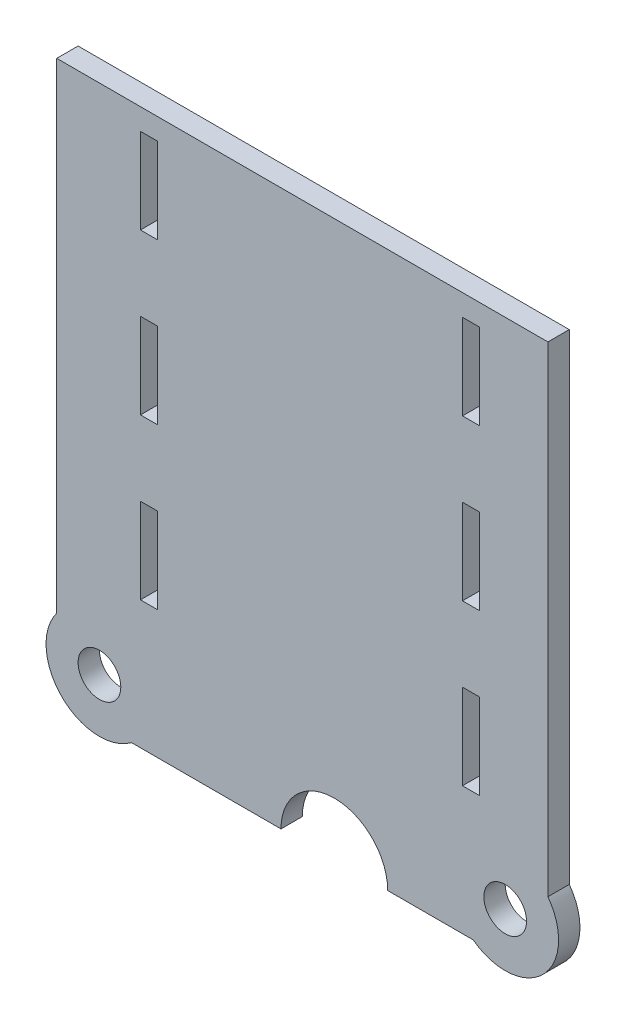
from build123d import *

# Parameters (mm, degrees)
SKETCH1_R           = 6.35
BOSS_EXTRUDE1_DEPTH = 3.175
SKETCH2_W           = 5.08
SKETCH2_H           = 25.4
CUT_EXTRUDE1_DEPTH  = 7.35
SKETCH3_R           = 15.875
CUT_EXTRUDE2_DEPTH  = 7.35


with BuildPart() as part:
    # Sketch1 → Boss-Extrude1 (new body, symmetric)
    with BuildSketch(Plane.XY):
        with BuildLine():
            Line((-0.002676144, -12.7), (0.002676144, -12.7))
            Line((0.002676144, -12.7), (50.8, -12.7))
            ThreePointArc((50.8, -12.7), (71.550320151, -11.225320151), (73.025, 9.525))
            Line((73.025, 9.525), (73.025, 152.4))
            Line((73.025, 152.4), (-73.025, 152.4))
            Line((-73.025, 152.4), (-73.025, 9.525))
            ThreePointArc((-73.025, 9.525), (-71.550320151, -11.225320151), (-50.8, -12.7))
            Line((-50.8, -12.7), (-0.002676144, -12.7))
        make_face()
        with Locations((-60.325, 0)):
            Circle(SKETCH1_R, mode=Mode.SUBTRACT)
        with Locations((60.325, 0)):
            Circle(SKETCH1_R, mode=Mode.SUBTRACT)
    extrude(amount=BOSS_EXTRUDE1_DEPTH, both=True)

    # Sketch2 → Cut-Extrude1 (cut, through all)
    with BuildSketch(Plane.XY.offset(3.175)):
        with Locations((-45.593, 133.35)):
            Rectangle(SKETCH2_W, SKETCH2_H)
        with Locations((-45.593, 85.725)):
            Rectangle(SKETCH2_W, SKETCH2_H)
        with Locations((-45.593, 38.1)):
            Rectangle(SKETCH2_W, SKETCH2_H)
        with Locations((50.165, 133.35)):
            Rectangle(SKETCH2_W, SKETCH2_H)
        with Locations((50.165, 38.1)):
            Rectangle(SKETCH2_W, SKETCH2_H)
        with Locations((50.165, 85.725)):
            Rectangle(SKETCH2_W, SKETCH2_H)
    extrude(amount=-CUT_EXTRUDE1_DEPTH, mode=Mode.SUBTRACT)

    # Sketch3 → Cut-Extrude2 (cut, through all)
    with BuildSketch(Plane.XY.offset(3.175)):
        with Locations((9.525, -12.7)):
            Circle(SKETCH3_R)
    extrude(amount=-CUT_EXTRUDE2_DEPTH, mode=Mode.SUBTRACT)


solid = part.part
